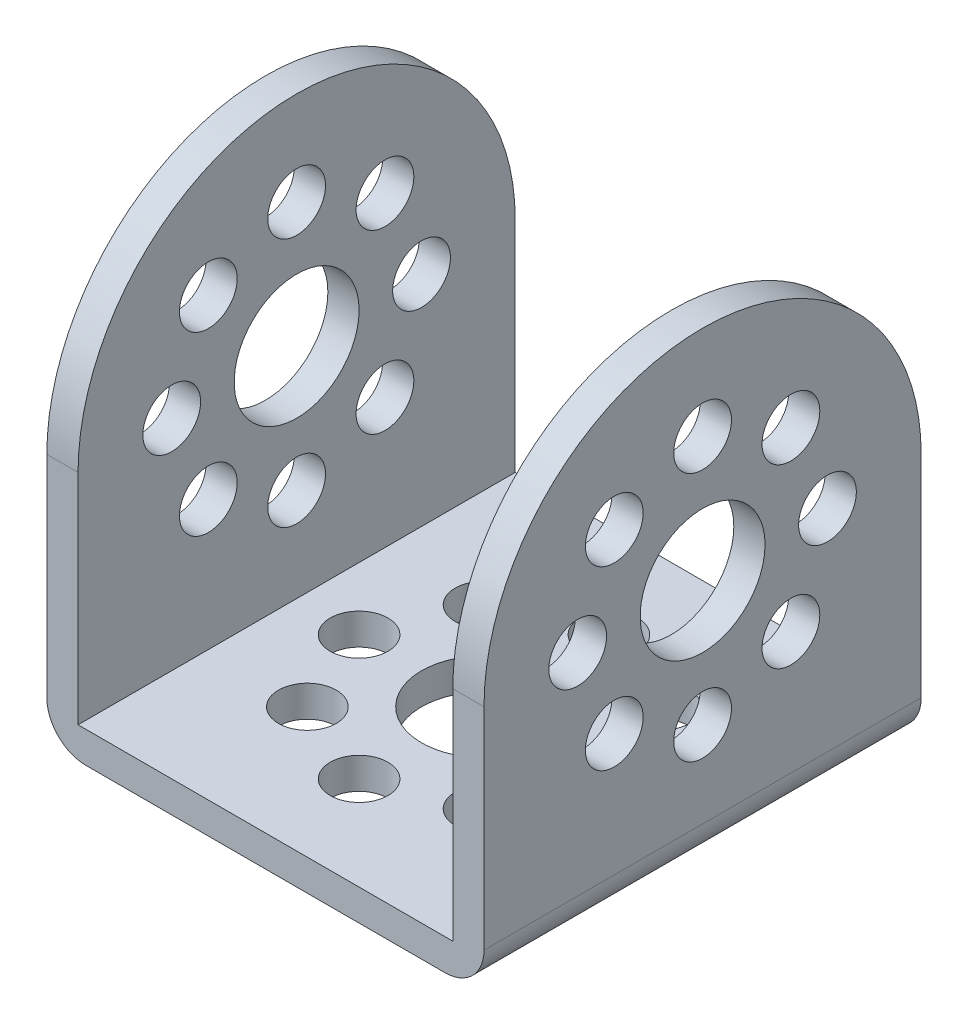
from build123d import *

# Parameters (mm, degrees)
BOSS_EXTRUDE1_DEPTH      = 14
BOSS_EXTRUDE1_DEPTH_BACK = 14
SKETCH1_R                = 4
SKETCH1_R_2              = 1.85
CUT_EXTRUDE1_DEPTH       = 12
CUT_EXTRUDE1_DEPTH_BACK  = 12
SKETCH3_R                = 4
SKETCH3_R_2              = 1.85
CUT_EXTRUDE2_DEPTH       = 2
FILLET1_R                = 2.5


with BuildPart() as part:
    # Sketch1 → Boss-Extrude1 (new, two sides: drawn at the far end of the back side and taken through both)
    with BuildSketch(Plane(origin=(0, 0, 0), x_dir=(0, 0, -1), z_dir=(1, 0, 0)).offset(-BOSS_EXTRUDE1_DEPTH_BACK)):
        with BuildLine():
            Line((-14, 0), (-14, -16))
            Line((-14, -16), (14, -16))
            Line((14, -16), (14, 0))
            ThreePointArc((14, 0), (0, 14), (-14, 0))
        make_face()
        Circle(SKETCH1_R, mode=Mode.SUBTRACT)
        with Locations((0, 8)):
            Circle(SKETCH1_R_2, mode=Mode.SUBTRACT)
        with Locations((5.656854249, 5.656854249)):
            Circle(SKETCH1_R_2, mode=Mode.SUBTRACT)
        with Locations((8, 0)):
            Circle(SKETCH1_R_2, mode=Mode.SUBTRACT)
        with Locations((5.656854249, -5.656854249)):
            Circle(SKETCH1_R_2, mode=Mode.SUBTRACT)
        with Locations((0, -8)):
            Circle(SKETCH1_R_2, mode=Mode.SUBTRACT)
        with Locations((-5.656854249, -5.656854249)):
            Circle(SKETCH1_R_2, mode=Mode.SUBTRACT)
        with Locations((-8, 0)):
            Circle(SKETCH1_R_2, mode=Mode.SUBTRACT)
        with Locations((-5.656854249, 5.656854249)):
            Circle(SKETCH1_R_2, mode=Mode.SUBTRACT)
    extrude(amount=BOSS_EXTRUDE1_DEPTH + BOSS_EXTRUDE1_DEPTH_BACK)

    # Sketch2 → Cut-Extrude1 (cut, two sides: drawn at the far end of the back side and taken through both)
    with BuildSketch(Plane(origin=(0, 0, 0), x_dir=(0, 0, -1), z_dir=(1, 0, 0)).offset(-CUT_EXTRUDE1_DEPTH_BACK)):
        with BuildLine():
            Line((-14, 0), (-14, -14))
            Line((-14, -14), (14, -14))
            Line((14, -14), (14, 0))
            ThreePointArc((14, 0), (0, 14), (-14, 0))
        make_face()
    extrude(amount=CUT_EXTRUDE1_DEPTH + CUT_EXTRUDE1_DEPTH_BACK, mode=Mode.SUBTRACT)

    # Sketch3 → Cut-Extrude2 (cut)
    with BuildSketch(Plane.XZ.offset(16)):
        Circle(SKETCH3_R)
        with Locations((0, 8)):
            Circle(SKETCH3_R_2)
        with Locations((5.656854249, 5.656854249)):
            Circle(SKETCH3_R_2)
        with Locations((8, 0)):
            Circle(SKETCH3_R_2)
        with Locations((5.656854249, -5.656854249)):
            Circle(SKETCH3_R_2)
        with Locations((0, -8)):
            Circle(SKETCH3_R_2)
        with Locations((-5.656854249, -5.656854249)):
            Circle(SKETCH3_R_2)
        with Locations((-8, 0)):
            Circle(SKETCH3_R_2)
        with Locations((-5.656854249, 5.656854249)):
            Circle(SKETCH3_R_2)
    extrude(amount=-CUT_EXTRUDE2_DEPTH, mode=Mode.SUBTRACT)

    # Fillet1
    fillet1_edges = [part.edges().sort_by_distance(p)[0] for p in [
        (-14, -16, 0),
        (14, -16, 0),
    ]]
    fillet(fillet1_edges, radius=FILLET1_R)


solid = part.part
